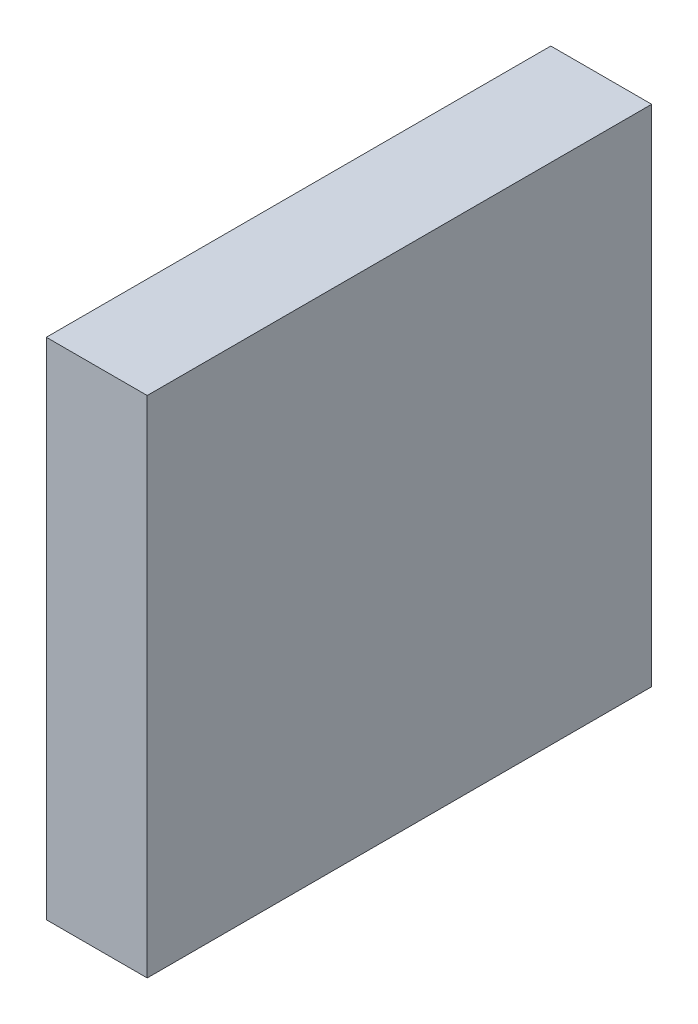
from build123d import *

# Parameters (mm, degrees)
SRECTANGLE_W     = 1
SRECTANGLE_H     = 5
FRECTANGLE_DEPTH = 5


with BuildPart() as part:
    # SRectangle → FRectangle (new body)
    with BuildSketch(Plane(origin=(0, 0, 0), x_dir=(1, 0, 0), z_dir=(0, 1, 0))):
        Rectangle(SRECTANGLE_W, SRECTANGLE_H)
    extrude(amount=-FRECTANGLE_DEPTH)


solid = part.part
